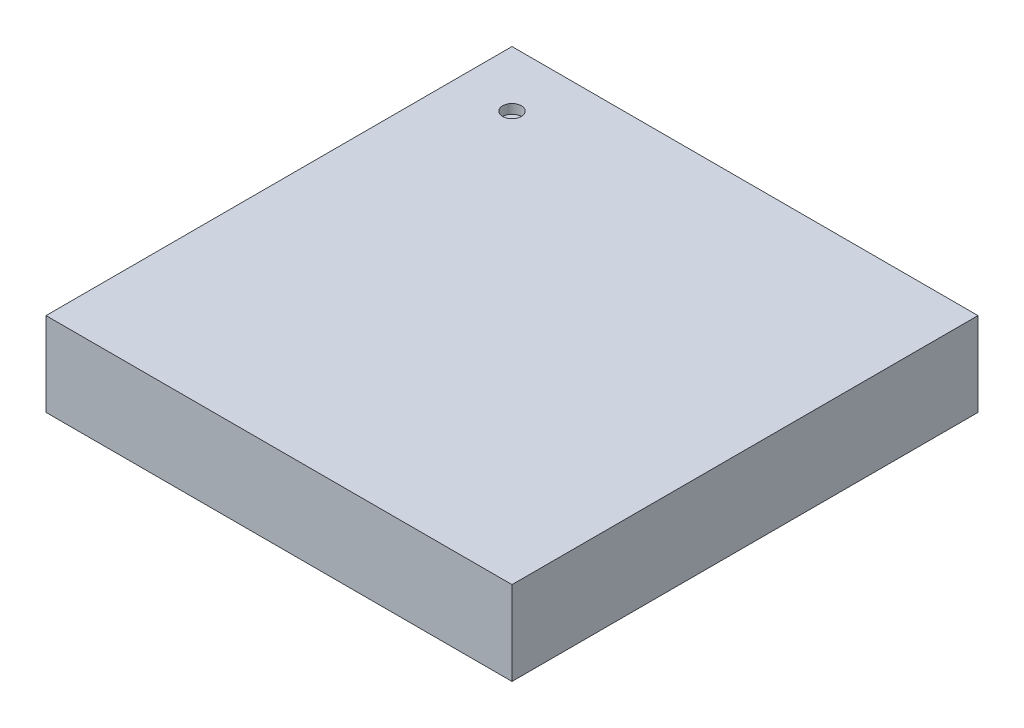
from build123d import *

# Parameters (mm, degrees)
ESQUISSE1_W             = 5
ESQUISSE1_H             = 5
BOSS_EXTRU_1_DEPTH      = 0.9
ESQUISSE2_R             = 0.1
ENL_V_MAT_EXTRU_1_DEPTH = 0.1


with BuildPart() as part:
    # Esquisse1 → Boss.-Extru.1 (new body)
    with BuildSketch(Plane(origin=(0, 0, 0), x_dir=(1, 0, 0), z_dir=(0, 1, 0))):
        with Locations((2.5, 2.5)):
            Rectangle(ESQUISSE1_W, ESQUISSE1_H)
    extrude(amount=BOSS_EXTRU_1_DEPTH)

    # Esquisse2 → Enlèv. mat.-Extru.1 (cut)
    with BuildSketch(Plane(origin=(0, 0.9, 0), x_dir=(1, 0, 0), z_dir=(0, 1, 0))):
        with Locations((0.6, 4.4)):
            Circle(ESQUISSE2_R)
    extrude(amount=-ENL_V_MAT_EXTRU_1_DEPTH, mode=Mode.SUBTRACT)


solid = part.part
